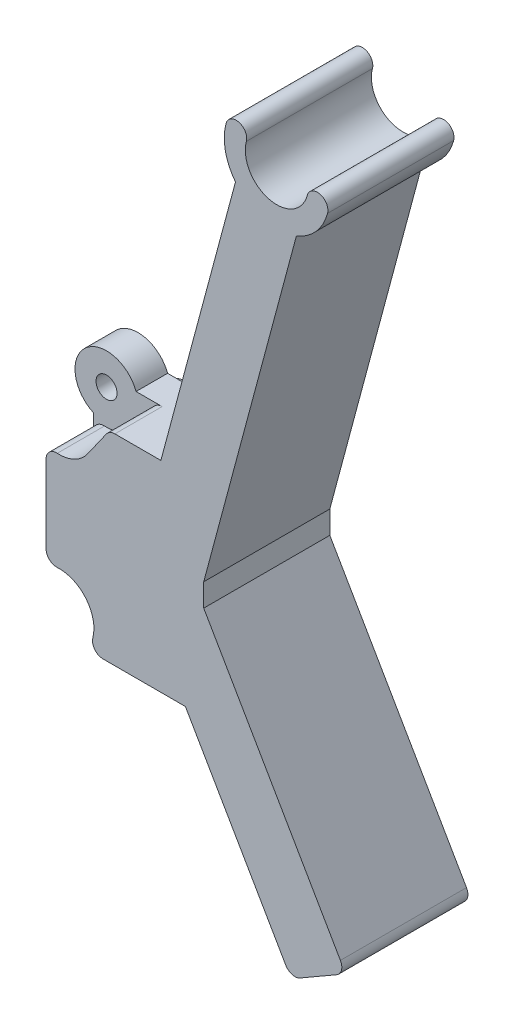
from build123d import *

# Parameters (mm, degrees)
SKETCH1_R           = 1
BOSS_EXTRUDE1_DEPTH = 12
SKETCH2_R           = 3.3
CUT_EXTRUDE1_DEPTH  = 4.5
FILLET1_R           = 1
FILLET2_R           = 1


with BuildPart() as part:
    # Sketch1 → Boss-Extrude1 (new body)
    with BuildSketch(Plane.XY):
        with BuildLine():
            Line((-5.308637939, 12.706986515), (-5.308637939, 23.252630458))
            ThreePointArc((-5.308637939, 23.252630458), (-6.101385458, 28.176893504), (-1.247793812, 27.02821456))
            Line((-1.247793812, 27.02821456), (5.613218796, 27.02821456))
            Line((5.613218796, 27.02821456), (12.714242382, 53.529595368))
            ThreePointArc((12.714242382, 53.529595368), (11.748807445, 55.614439687), (11.81766691, 57.910936764))
            ThreePointArc((11.81766691, 57.910936764), (13.042411781, 58.618043545), (13.749518562, 57.393298673))
            ThreePointArc((13.749518562, 57.393298673), (15.870838906, 53.719064059), (19.54507352, 55.840384403))
            ThreePointArc((19.54507352, 55.840384403), (20.769818391, 56.547491184), (21.476925173, 55.322746313))
            ThreePointArc((21.476925173, 55.322746313), (20.38831068, 53.299491772), (18.50979734, 51.976681098))
            Line((18.50979734, 51.976681098), (9.691362061, 19.065832594))
            Line((9.691362061, 19.065832594), (9.691362061, 16.893784379))
            Line((9.691362061, 16.893784379), (23.198320346, -6.500953627))
            Line((23.198320346, -6.500953627), (18.002167924, -9.500953627))
            Line((18.002167924, -9.500953627), (7.947710262, 7.913877886))
            Line((7.947710262, 7.913877886), (-1.883337786, 7.913877886))
            ThreePointArc((-1.883337786, 7.913877886), (-6.49944061, 8.235537199), (-5.308637939, 12.706986515))
        make_face()
        with Locations((-4.058637939, 25.979808487)):
            Circle(SKETCH1_R, mode=Mode.SUBTRACT)
        with Locations((-4.058637939, 9.979808487)):
            Circle(SKETCH1_R, mode=Mode.SUBTRACT)
    extrude(amount=BOSS_EXTRUDE1_DEPTH)

    # Sketch2 → Cut-Extrude1 (cut)
    with BuildSketch(Plane.XY.offset(12)):
        with Locations((-4.058637939, 9.979808487)):
            Circle(SKETCH2_R)
        with BuildLine():
            Line((-1.360308715, 24.080066558), (2.301920689, 29.28177342))
            Line((2.301920689, 29.28177342), (-2.704987918, 28.989398429))
            ThreePointArc((-2.704987918, 28.989398429), (-7.241406986, 25.108039484), (-1.360308715, 24.080066558))
        make_face()
    cut_extrude1 = extrude(amount=-CUT_EXTRUDE1_DEPTH, mode=Mode.SUBTRACT)

    # Mirror1: Cut-Extrude1 across plane
    add(cut_extrude1.mirror(Plane.XY.offset(6)), mode=Mode.SUBTRACT)

    # Fillet1
    fillet1_edges = [part.edges().sort_by_distance(p)[0] for p in [
        (-5.308637939, 22.925712876, 9.75),
        (-5.308637939, 13.033904097, 9.75),
        (0.715316572, 27.02821456, 9.75),
        (-1.485326696, 7.913877886, 9.75),
        (-5.308637939, 22.925712876, 2.25),
        (-5.308637939, 13.033904097, 2.25),
        (0.715316572, 27.02821456, 2.25),
        (-1.485326696, 7.913877886, 2.25),
    ]]
    fillet(fillet1_edges, radius=FILLET1_R)

    # Fillet2
    fillet2_edges = [part.edges().sort_by_distance(p)[0] for p in [
        (23.198320346, -6.500953627, 6),
        (18.002167924, -9.500953627, 6),
    ]]
    fillet(fillet2_edges, radius=FILLET2_R)


solid = part.part
